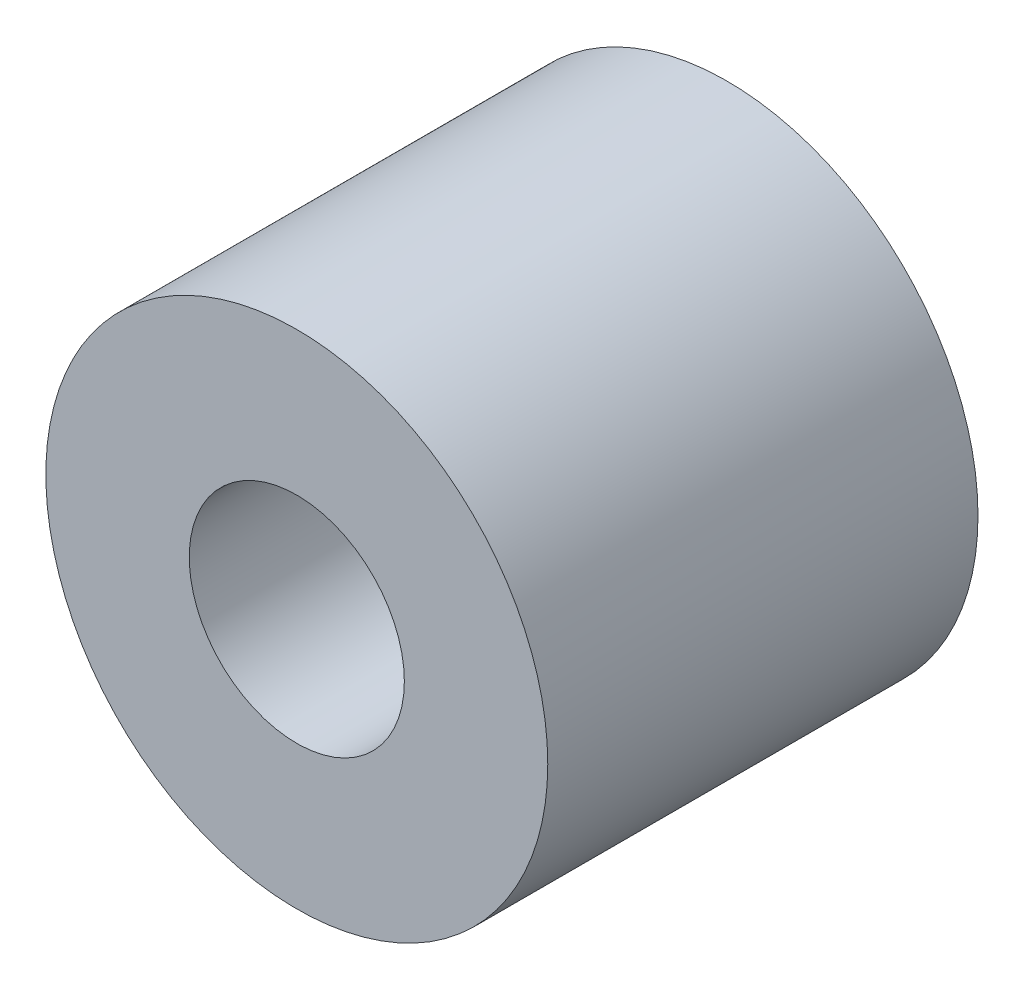
from build123d import *

# Parameters (mm, degrees)
SKETCH1_R           = 2.778125
SKETCH1_R_2         = 1.190625
BOSS_EXTRUDE1_DEPTH = 4.7625


with BuildPart() as part:
    # Sketch1 → Boss-Extrude1 (new body)
    with BuildSketch(Plane.XY):
        Circle(SKETCH1_R)
        Circle(SKETCH1_R_2, mode=Mode.SUBTRACT)
    extrude(amount=BOSS_EXTRUDE1_DEPTH)


solid = part.part
